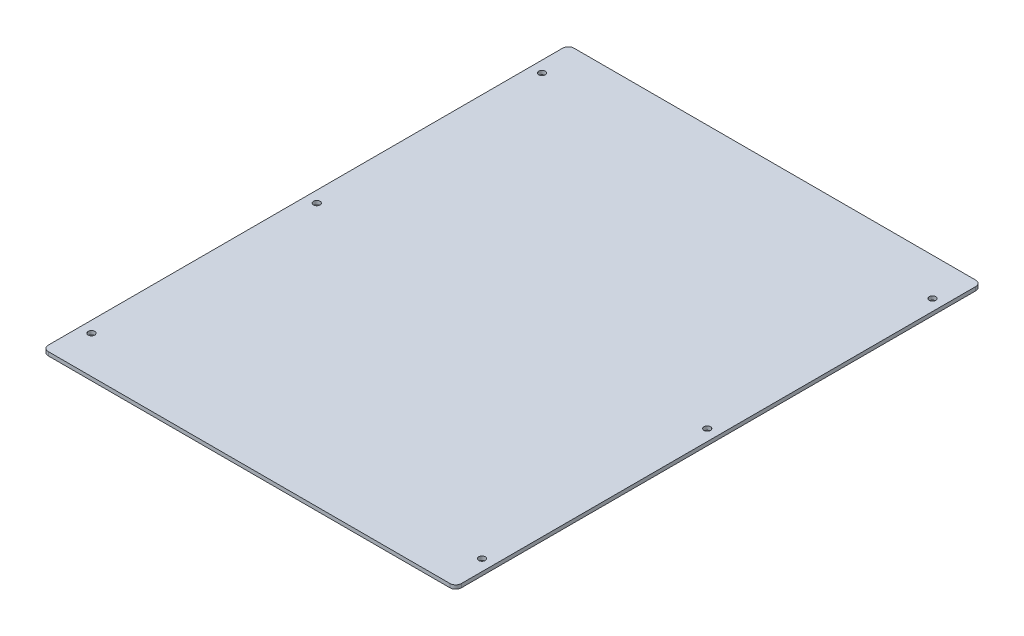
from build123d import *

# Parameters (mm, degrees)
SKETCH1_W                  = 220
SKETCH1_H                  = 280
BOSS_EXTRUDE1_DEPTH        = 2
F_3_5_3_5_DIAMETER_HOLE1_D = 3.5
FILLET1_R                  = 3


with BuildPart() as part:
    # Sketch1 → Boss-Extrude1 (new body)
    with BuildSketch(Plane(origin=(0, 0, 0), x_dir=(1, 0, 0), z_dir=(0, 1, 0))):
        Rectangle(SKETCH1_W, SKETCH1_H)
    extrude(amount=BOSS_EXTRUDE1_DEPTH)

    # Ø3.5 (3.5) Diameter Hole1 (through all)
    with Locations(Plane(origin=(0, 2, 0), x_dir=(1, 0, 0), z_dir=(0, 1, 0))):
        with Locations((-104, -120), (104, -120), (104, 120), (-104, 120), (104, 0), (-104, 0)):
            Hole(F_3_5_3_5_DIAMETER_HOLE1_D / 2)

    # Fillet1
    fillet1_edges = [part.edges().sort_by_distance(p)[0] for p in [
        (110, 1, 140),
        (-110, 1, 140),
        (-110, 1, -140),
        (110, 1, -140),
    ]]
    fillet(fillet1_edges, radius=FILLET1_R)


solid = part.part
